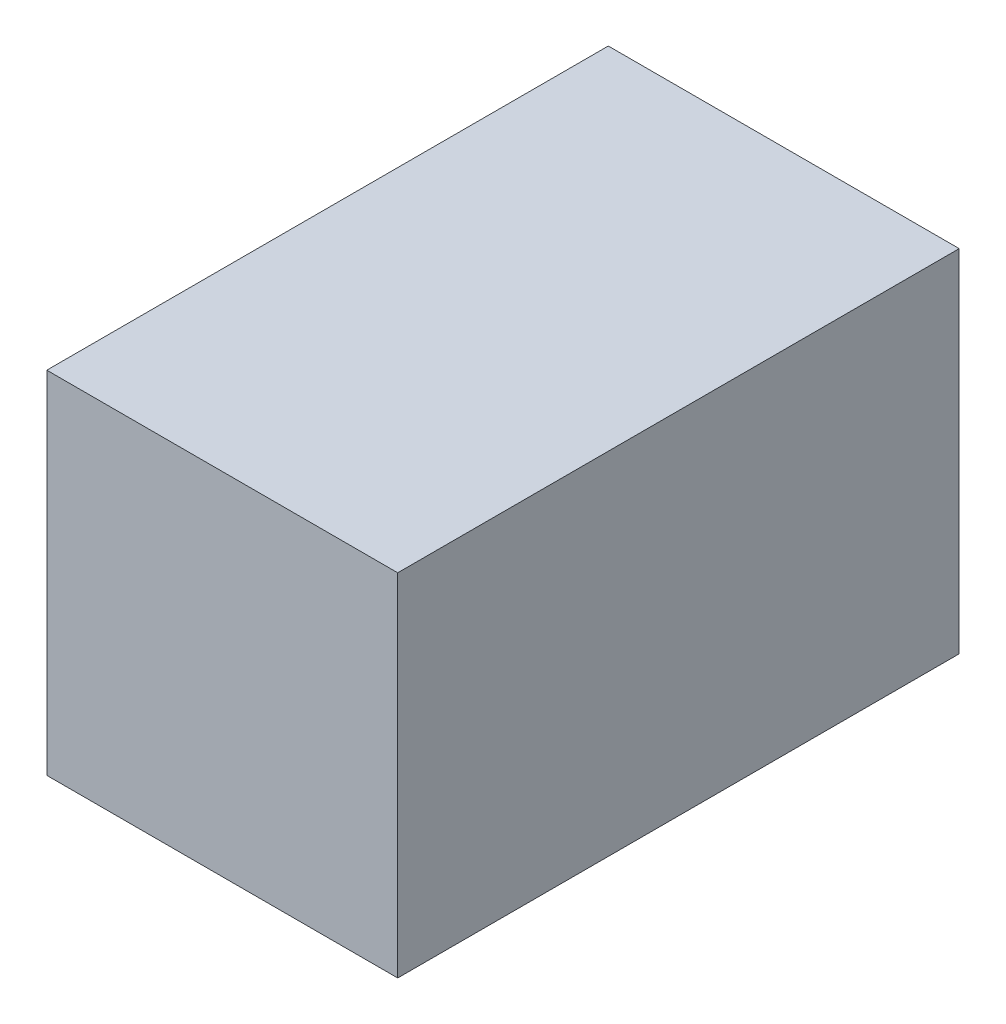
from build123d import *

# Parameters (mm, degrees)
BASES_W    = 1
BASES_H    = 1.6
BASE_DEPTH = 1


with BuildPart() as part:
    # BaseS → Base (new body)
    with BuildSketch(Plane(origin=(0, 0, 0), x_dir=(1, 0, 0), z_dir=(0, 1, 0))):
        Rectangle(BASES_W, BASES_H)
    extrude(amount=BASE_DEPTH)


solid = part.part
